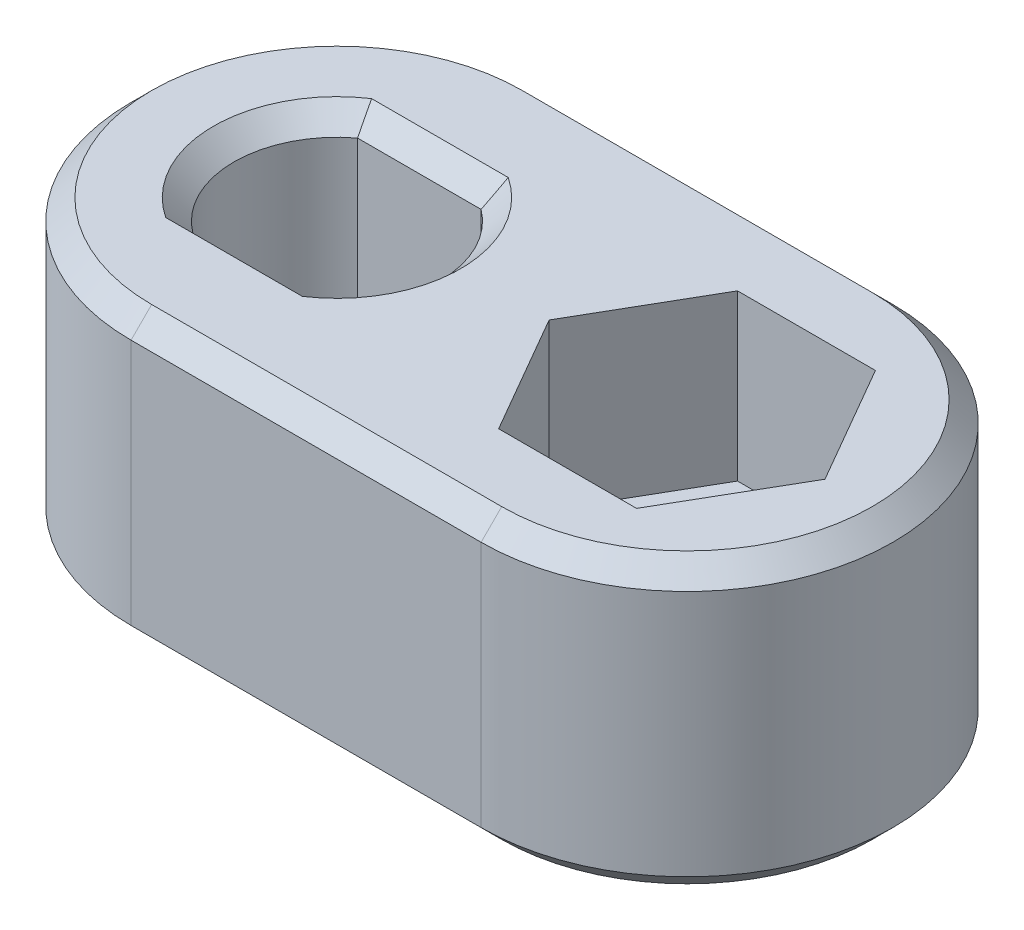
from build123d import *

# Parameters (mm, degrees)
BOSS_EXTRUDE1_DEPTH                                  = 7
CUT_EXTRUDE1_DEPTH                                   = 4
CSK_FOR_M3_HEX_SOCKET_COUNTERSUNK_CAP_SC_D           = 3.4
CSK_FOR_M3_HEX_SOCKET_COUNTERSUNK_CAP_SC_DEPTH       = 7.5
CSK_FOR_M3_HEX_SOCKET_COUNTERSUNK_CAP_SC_CSINK_D     = 6.72
CSK_FOR_M3_HEX_SOCKET_COUNTERSUNK_CAP_SC_CSINK_ANGLE = 90
CSK_FOR_M3_HEX_SOCKET_COUNTERSUNK_CAP_SC_TIP         = 1.021463052
HOLE1_D                                              = 4.15
CUT_EXTRUDE2_DEPTH                                   = 4
CHAMFER1_SIZE                                        = 0.5


with BuildPart() as part:
    # Sketch1 → Boss-Extrude1 (new body)
    with BuildSketch(Plane(origin=(0, 0, 0), x_dir=(1, 0, 0), z_dir=(0, 1, 0))):
        with BuildLine():
            Line((0, 5), (8.5, 5))
            ThreePointArc((8.5, 5), (13.5, 0), (8.5, -5))
            Line((8.5, -5), (0, -5))
            ThreePointArc((0, -5), (-5, 0), (0, 5))
        make_face()
    extrude(amount=BOSS_EXTRUDE1_DEPTH)

    # Sketch2 → Cut-Extrude1 (cut)
    with BuildSketch(Plane(origin=(0, 7, 0), x_dir=(1, 0, 0), z_dir=(0, 1, 0))):
        with BuildLine():
            ThreePointArc((-1.5, 2), (-2.5, 0), (-1.5, -2))
            Line((-1.5, -2), (1.5, -2))
            ThreePointArc((1.5, -2), (2.236067977, -1.118033989), (2.5, 0))
            ThreePointArc((2.5, 0), (2.236067977, 1.118033989), (1.5, 2))
            Line((1.5, 2), (-1.5, 2))
        make_face()
    extrude(amount=-CUT_EXTRUDE1_DEPTH, mode=Mode.SUBTRACT)

    # CSK for M3 Hex Socket Countersunk Cap Screw2
    with Locations(Plane(origin=(0, 0, 0), x_dir=(-1, 0, 0), z_dir=(0, -1, 0))):
        with Locations((0, 0)):
            CounterSinkHole(CSK_FOR_M3_HEX_SOCKET_COUNTERSUNK_CAP_SC_D / 2, CSK_FOR_M3_HEX_SOCKET_COUNTERSUNK_CAP_SC_CSINK_D / 2, depth=CSK_FOR_M3_HEX_SOCKET_COUNTERSUNK_CAP_SC_DEPTH, counter_sink_angle=CSK_FOR_M3_HEX_SOCKET_COUNTERSUNK_CAP_SC_CSINK_ANGLE)
            with Locations((0, 0, -(CSK_FOR_M3_HEX_SOCKET_COUNTERSUNK_CAP_SC_DEPTH + CSK_FOR_M3_HEX_SOCKET_COUNTERSUNK_CAP_SC_TIP / 2))):  # 118° drill point
                Cone(0, CSK_FOR_M3_HEX_SOCKET_COUNTERSUNK_CAP_SC_D / 2, CSK_FOR_M3_HEX_SOCKET_COUNTERSUNK_CAP_SC_TIP, mode=Mode.SUBTRACT)

    # Hole1 (through all)
    with Locations(Plane(origin=(0, 0, 0), x_dir=(-1, 0, 0), z_dir=(0, -1, 0))):
        with Locations((-8.5, 0)):
            Hole(HOLE1_D / 2)

    # Sketch11 → Cut-Extrude2 (cut)
    with BuildSketch(Plane(origin=(0, 7, 0), x_dir=(1, 0, 0), z_dir=(0, 1, 0))):
        Polygon((11.848631561, 0), (10.174315781, 2.9), (6.825684219, 2.9), (5.151368439, 0), (6.825684219, -2.9), (10.174315781, -2.9), align=None)
    extrude(amount=-CUT_EXTRUDE2_DEPTH, mode=Mode.SUBTRACT)

    # Chamfer1
    chamfer1_edges = [part.edges().sort_by_distance(p)[0] for p in [
        (13.5, 7, 0),
        (0, 7, -2),
        (4.25, 7, -5),
        (-2.5, 7, 0),
        (0, 7, 2),
        (2.5, 7, 0),
        (-5, 7, 0),
        (4.25, 0, -5),
        (13.5, 0, 0),
        (4.25, 0, 5),
        (-5, 0, 0),
        (4.25, 7, 5),
    ]]
    chamfer(chamfer1_edges, length=CHAMFER1_SIZE)


solid = part.part
